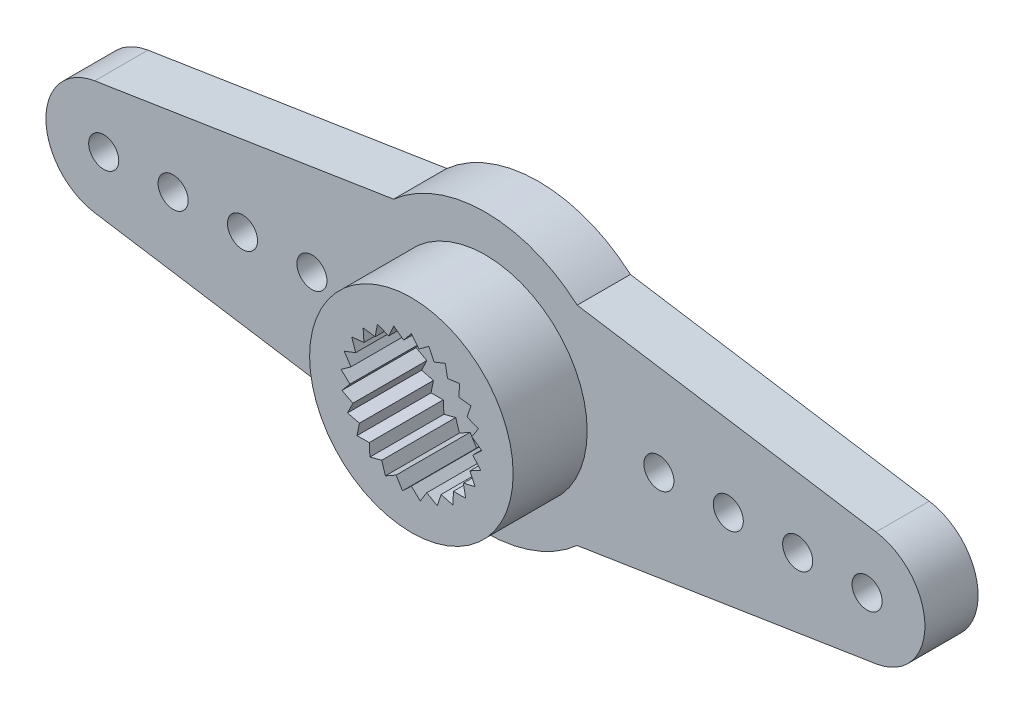
from build123d import *

# Parameters (mm, degrees)
SKETCH_1_R          = 0.65
SKETCH_1_R_2        = 1.5
EXTRUDE_1_DEPTH     = 2.3
SKETCH_2_R          = 4.4
EXTRUDE_2_DEPTH     = 3.2
SKETCH_3_R          = 4.4
SKETCH_3_R_2        = 3.4
SKETCH_3_R_3        = 2.75
SKETCH_3_R_4        = 1.5
CUT_EXTRUDE_1_DEPTH = 1


with BuildPart() as part:
    # Эскиз1 → Бобышка-Вытянуть1 (new body)
    with BuildSketch(Plane.XY):
        with BuildLine():
            Line((-3.968626967, 4.5), (-16.888114198, 2.469689731))
            ThreePointArc((-16.888114198, 2.469689731), (-19, 0), (-16.888114198, -2.469689731))
            Line((-16.888114198, -2.469689731), (-3.968626967, -4.5))
            ThreePointArc((-3.968626967, -4.5), (0, -6), (3.968626967, -4.5))
            Line((3.968626967, -4.5), (16.888114198, -2.469689731))
            ThreePointArc((16.888114198, -2.469689731), (19, 0), (16.888114198, 2.469689731))
            Line((16.888114198, 2.469689731), (3.968626967, 4.5))
            ThreePointArc((3.968626967, 4.5), (0, 6), (-3.968626967, 4.5))
        make_face()
        with Locations((-16.5, 0)):
            Circle(SKETCH_1_R, mode=Mode.SUBTRACT)
        with Locations((-13.5, 0)):
            Circle(SKETCH_1_R, mode=Mode.SUBTRACT)
        with Locations((-10.5, 0)):
            Circle(SKETCH_1_R, mode=Mode.SUBTRACT)
        with Locations((-7.5, 0)):
            Circle(SKETCH_1_R, mode=Mode.SUBTRACT)
        with Locations((16.5, 0)):
            Circle(SKETCH_1_R, mode=Mode.SUBTRACT)
        with Locations((7.5, 0)):
            Circle(SKETCH_1_R, mode=Mode.SUBTRACT)
        with Locations((10.5, 0)):
            Circle(SKETCH_1_R, mode=Mode.SUBTRACT)
        with Locations((13.5, 0)):
            Circle(SKETCH_1_R, mode=Mode.SUBTRACT)
        Circle(SKETCH_1_R_2, mode=Mode.SUBTRACT)
    extrude(amount=EXTRUDE_1_DEPTH)

    # Эскиз2 → Бобышка-Вытянуть2 (add)
    with BuildSketch(Plane.XY.offset(2.3)):
        Circle(SKETCH_2_R)
        Polygon((0.333439775, 2.639447604), (0, 3.05), (-0.333439775, 2.639447604), (-0.758504156, 2.954178641), (-0.979368078, 2.473601404), (-1.469348706, 2.672735374), (-1.563759083, 2.15232973), (-2.087868673, 2.223354314), (-2.049893354, 1.695819264), (-2.575200173, 1.634271725), (-2.407225286, 1.132754236), (-2.900722375, 0.942501833), (-2.6133024, 0.498514094), (-3.043981522, 0.191511085), (-2.655176114, -0.167049522), (-2.995976115, -0.571513009), (-2.530215347, -0.822116802), (-2.75972251, -1.298626839), (-2.246271844, -1.42552746), (-2.35006539, -1.944143169), (-1.821186821, -1.939366985), (-1.792745019, -2.467501833), (-1.281669931, -2.33134895), (-1.122779886, -2.835818282), (-0.661621006, -2.576843686), (-0.382266362, -3.025949839), (0, -2.660425857), (0.382266362, -3.025949839), (0.661621006, -2.576843686), (1.122779886, -2.835818282), (1.281669931, -2.33134895), (1.792745019, -2.467501833), (1.821186821, -1.939366985), (2.35006539, -1.944143169), (2.246271844, -1.42552746), (2.75972251, -1.298626839), (2.530215347, -0.822116802), (2.995976115, -0.571513009), (2.655176114, -0.167049522), (3.043981522, 0.191511085), (2.6133024, 0.498514094), (2.900722375, 0.942501833), (2.407225286, 1.132754236), (2.575200173, 1.634271725), (2.049893354, 1.695819264), (2.087868673, 2.223354314), (1.563759083, 2.15232973), (1.469348706, 2.672735374), (0.979368078, 2.473601404), (0.758504156, 2.954178641), align=None, mode=Mode.SUBTRACT)
    extrude(amount=EXTRUDE_2_DEPTH)

    # Эскиз3 → Вырез-Вытянуть1 (cut)
    with BuildSketch(Plane(origin=(0, 0, 0), x_dir=(-1, 0, 0), z_dir=(0, 0, -1))):
        Circle(SKETCH_3_R)
        Circle(SKETCH_3_R_2, mode=Mode.SUBTRACT)
        Circle(SKETCH_3_R_3)
        Circle(SKETCH_3_R_4, mode=Mode.SUBTRACT)
    extrude(amount=-CUT_EXTRUDE_1_DEPTH, mode=Mode.SUBTRACT)


solid = part.part
